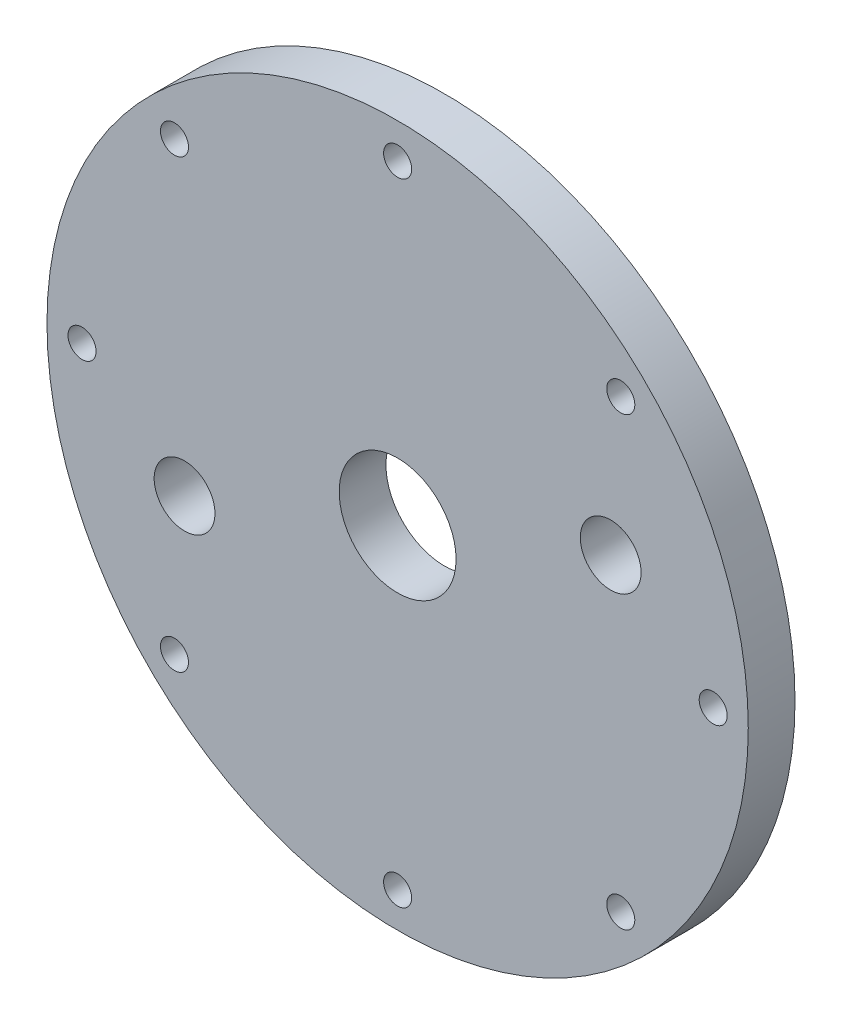
from build123d import *

# Parameters (mm, degrees)
CROQUIS1_R              = 75
CROQUIS1_R_2            = 3
CROQUIS1_R_3            = 12.5
SALIENTE_EXTRUIR1_DEPTH = 10
CROQUIS2_R              = 6.5
CORTAR_EXTRUIR1_DEPTH   = 10


with BuildPart() as part:
    # Croquis1 → Saliente-Extruir1 (new body)
    with BuildSketch(Plane.XY):
        Circle(CROQUIS1_R)
        with Locations((0, 67.5)):
            Circle(CROQUIS1_R_2, mode=Mode.SUBTRACT)
        with Locations((47.72970773, 47.72970773)):
            Circle(CROQUIS1_R_2, mode=Mode.SUBTRACT)
        with Locations((67.5, 0)):
            Circle(CROQUIS1_R_2, mode=Mode.SUBTRACT)
        with Locations((47.72970773, -47.72970773)):
            Circle(CROQUIS1_R_2, mode=Mode.SUBTRACT)
        with Locations((0, -67.5)):
            Circle(CROQUIS1_R_2, mode=Mode.SUBTRACT)
        with Locations((-47.72970773, -47.72970773)):
            Circle(CROQUIS1_R_2, mode=Mode.SUBTRACT)
        with Locations((-67.5, 0)):
            Circle(CROQUIS1_R_2, mode=Mode.SUBTRACT)
        with Locations((-47.72970773, 47.72970773)):
            Circle(CROQUIS1_R_2, mode=Mode.SUBTRACT)
        Circle(CROQUIS1_R_3, mode=Mode.SUBTRACT)
    extrude(amount=SALIENTE_EXTRUIR1_DEPTH)

    # Croquis2 → Cortar-Extruir1 (cut)
    with BuildSketch(Plane.XY.offset(10)):
        with Locations((45.570866947, 17.316425315)):
            Circle(CROQUIS2_R)
        with Locations((-45.570866947, -17.316425315)):
            Circle(CROQUIS2_R)
    extrude(amount=-CORTAR_EXTRUIR1_DEPTH, mode=Mode.SUBTRACT)


solid = part.part
